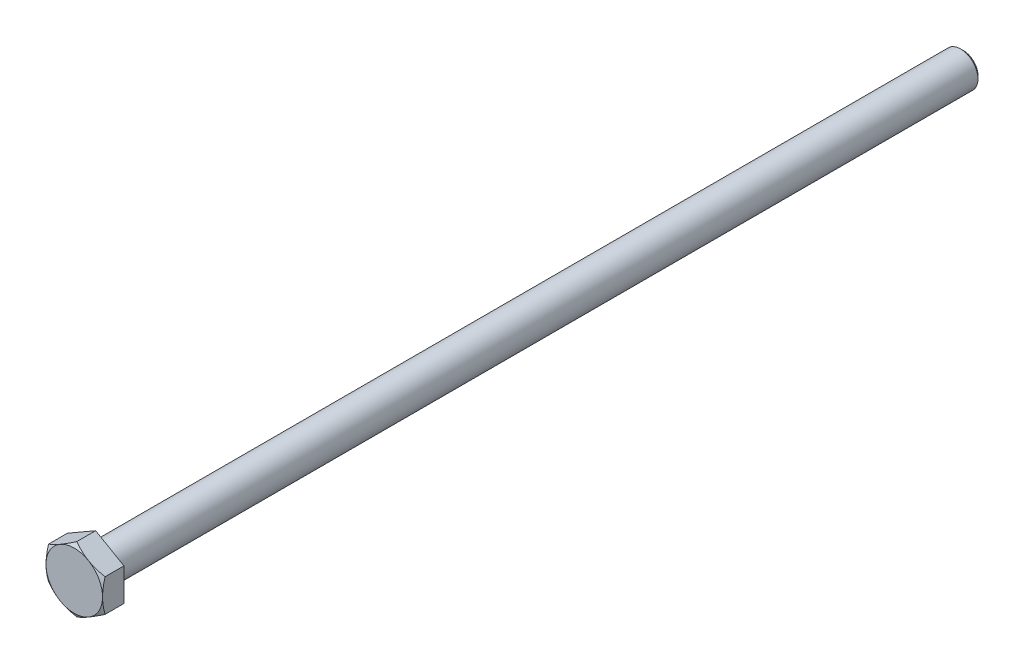
from build123d import *

# Parameters (mm, degrees)
BOSS_EXTRUDE1_DEPTH = 3.85


with BuildPart() as part:
    # Sketch1 → Boss-Extrude1 (new body)
    with BuildSketch(Plane.XY):
        Polygon((0, 5.646485633), (-4.89, 2.823242816), (-4.89, -2.823242816), (0, -5.646485633), (4.89, -2.823242816), (4.89, 2.823242816), align=None)
    extrude(amount=BOSS_EXTRUDE1_DEPTH)

    # Sketch2 → Revolve1 (revolve)
    with BuildSketch(Plane(origin=(0, 0, 0), x_dir=(0, 0, -1), z_dir=(1, 0, 0))):
        with BuildLine():
            Line((0, 0), (0, 3.25))
            ThreePointArc((0, 3.25), (0.073223305, 3.073223305), (0.25, 3))
            Line((0.25, 3), (149.5, 3))
            Line((149.5, 3), (150, 2.5))
            Line((150, 2.5), (150, 0))
            Line((150, 0), (0, 0))
        make_face()
    revolve(axis=Axis((0, 0, 0), (0, 0, -1)))

    # Sketch3 → Cut-Revolve1 (revolve, cut)
    with BuildSketch(Plane(origin=(0, 0, 0), x_dir=(0, 0, -1), z_dir=(1, 0, 0))):
        Polygon((-3.85, 5.646485633), (-3.413242816, 5.646485633), (-3.85, 4.89), align=None)
        Polygon((-0.15, 5.646485633), (-0.15, 4.53660254), (0, 4.45), (0, 5.646485633), align=None)
    revolve(axis=Axis((0, 0, 12.204941078), (0, 0, -1)), mode=Mode.SUBTRACT)


solid = part.part
